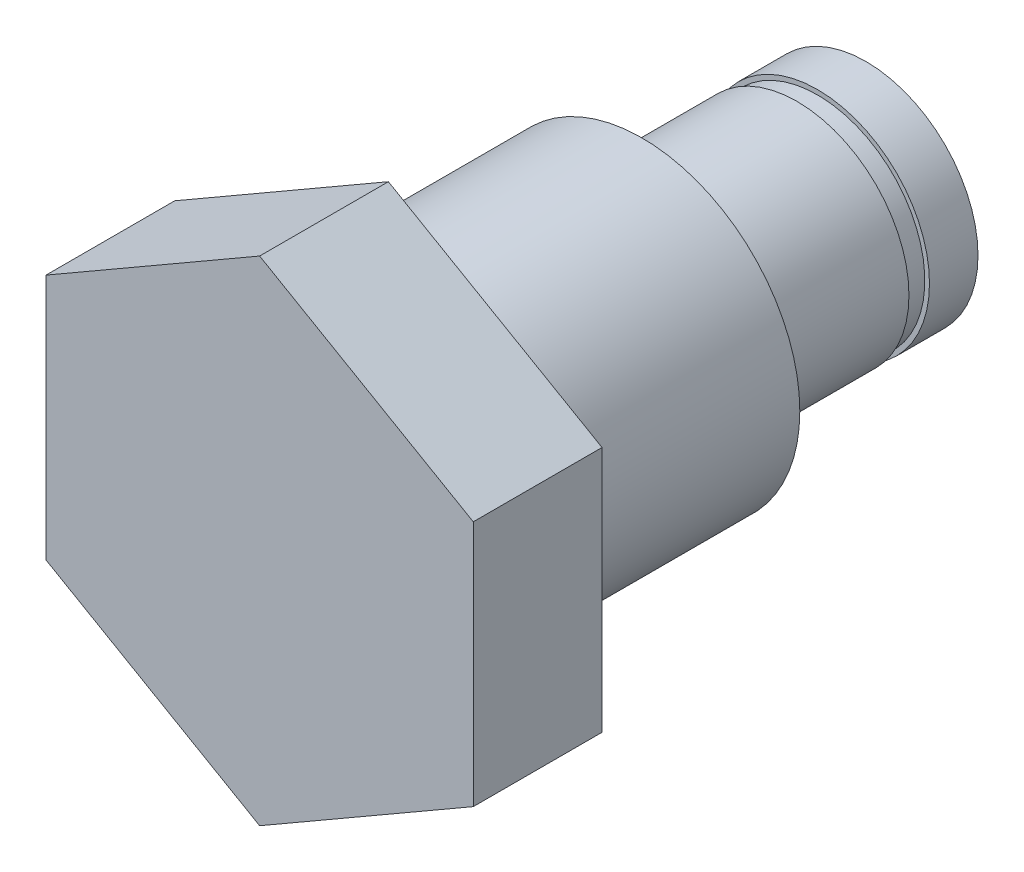
from build123d import *

# Parameters (mm, degrees)
SKETCH1_R           = 8.45
BOSS_EXTRUDE1_DEPTH = 13.6
BOSS_EXTRUDE2_DEPTH = 6.9
SKETCH3_R           = 6
BOSS_EXTRUDE3_DEPTH = 12
SKETCH5_R           = 6
SKETCH5_R_2         = 5.75
CUT_EXTRUDE1_DEPTH  = 1.1


with BuildPart() as part:
    # Sketch1 → Boss-Extrude1 (new body)
    with BuildSketch(Plane.XY):
        Circle(SKETCH1_R)
    extrude(amount=-BOSS_EXTRUDE1_DEPTH)

    # Sketch2 → Boss-Extrude2 (add)
    with BuildSketch(Plane.XY):
        Polygon((0, 13.221321164), (-11.45, 6.610660582), (-11.45, -6.610660582), (0, -13.221321164), (11.45, -6.610660582), (11.45, 6.610660582), align=None)
    extrude(amount=BOSS_EXTRUDE2_DEPTH)

    # Sketch3 → Boss-Extrude3 (add)
    with BuildSketch(Plane(origin=(0, 0, -13.6), x_dir=(-1, 0, 0), z_dir=(0, 0, -1))):
        Circle(SKETCH3_R)
    extrude(amount=BOSS_EXTRUDE3_DEPTH)

    # Sketch5 → Cut-Extrude1 (cut)
    with BuildSketch(Plane(origin=(0, 0, -21.9), x_dir=(-1, 0, 0), z_dir=(0, 0, -1))):
        Circle(SKETCH5_R)
        Circle(SKETCH5_R_2, mode=Mode.SUBTRACT)
    extrude(amount=CUT_EXTRUDE1_DEPTH, mode=Mode.SUBTRACT)


solid = part.part
